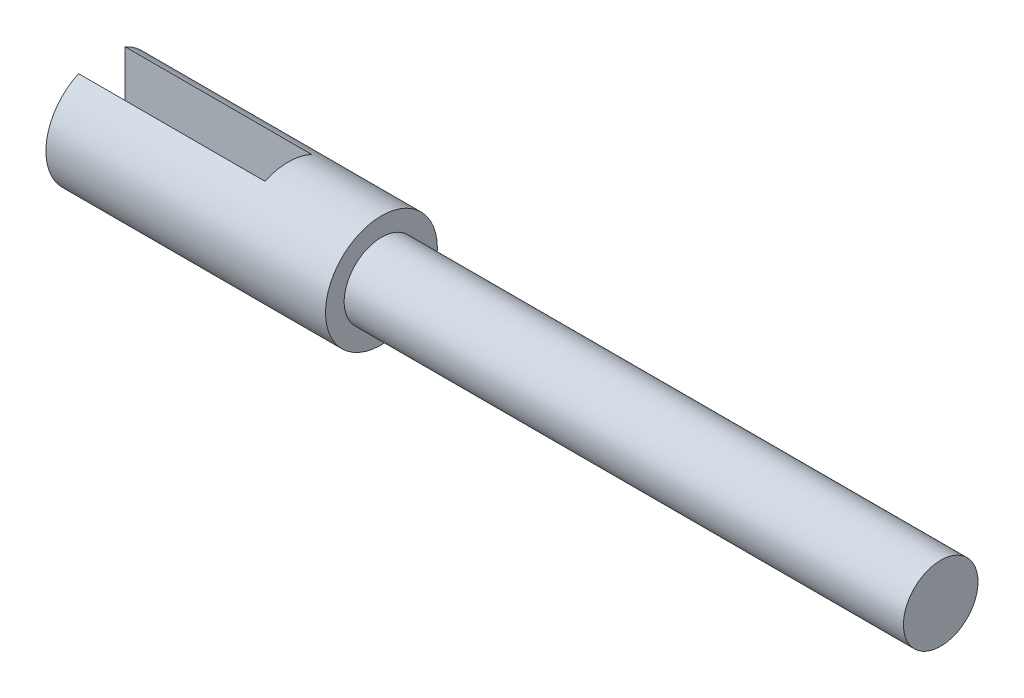
from build123d import *

# Parameters (mm, degrees)
SKETCH1_R               = 2.54
BOSS_EXTRUDE1_DEPTH     = 38.1
SKETCH2_R               = 3.81
BOSS_EXTRUDE2_DEPTH     = 19.05
SKETCH3_W               = 12.7
SKETCH3_H               = 3.175
CUT_EXTRUDE1_DEPTH      = 4.81
CUT_EXTRUDE1_DEPTH_BACK = 4.81


with BuildPart() as part:
    # Sketch1 → Boss-Extrude1 (new body)
    with BuildSketch(Plane(origin=(0, 0, 0), x_dir=(0, 0, -1), z_dir=(1, 0, 0))):
        Circle(SKETCH1_R)
    extrude(amount=BOSS_EXTRUDE1_DEPTH)

    # Sketch2 → Boss-Extrude2 (add)
    with BuildSketch(Plane(origin=(0, 0, 0), x_dir=(0, 0, -1), z_dir=(1, 0, 0))):
        Circle(SKETCH2_R)
    extrude(amount=-BOSS_EXTRUDE2_DEPTH)

    # Sketch3 → Cut-Extrude1 (cut, two sides)
    with BuildSketch(Plane(origin=(0, 0, 0), x_dir=(1, 0, 0), z_dir=(0, 1, 0))) as cut_extrude1_sk:
        with Locations((-12.7, 0)):
            Rectangle(SKETCH3_W, SKETCH3_H)
    extrude(amount=CUT_EXTRUDE1_DEPTH, mode=Mode.SUBTRACT)
    extrude(cut_extrude1_sk.sketch, amount=-CUT_EXTRUDE1_DEPTH_BACK, mode=Mode.SUBTRACT)


solid = part.part
